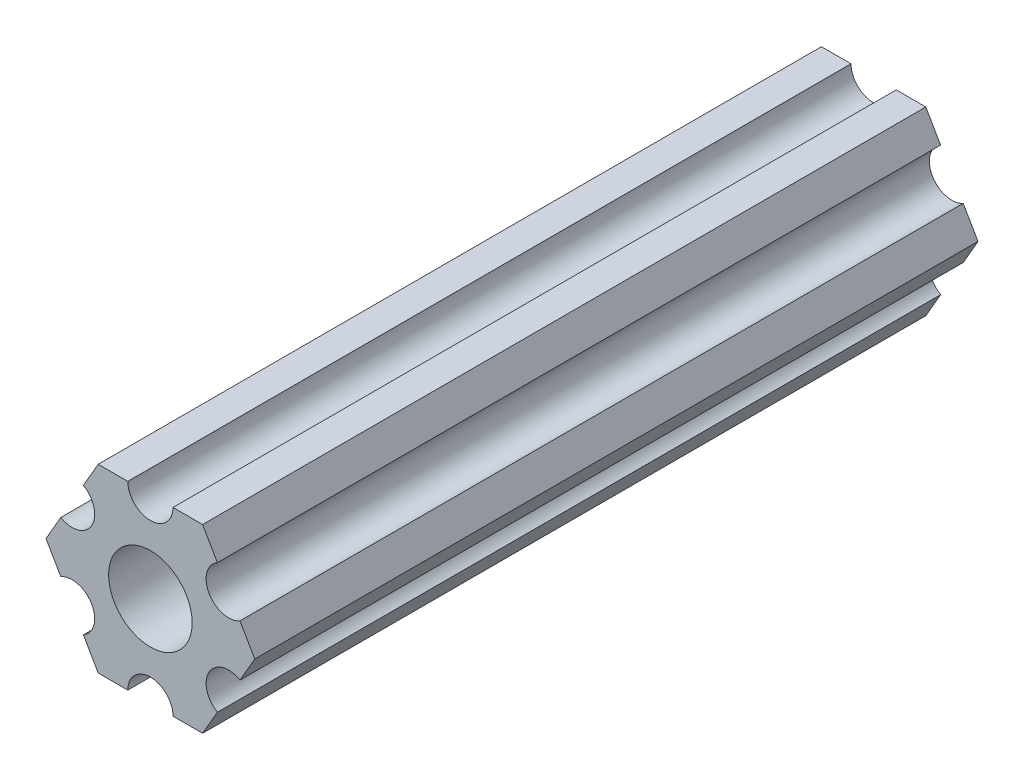
from build123d import *

# Parameters (mm, degrees)
SKETCH1_R           = 2.9337
BOSS_EXTRUDE1_DEPTH = 50.8


with BuildPart() as part:
    # Sketch1 → Boss-Extrude1 (new body)
    with BuildSketch(Plane(origin=(0, 0, 0), x_dir=(-1, 0, 0), z_dir=(0, 0, -1))):
        with BuildLine():
            Line((-4.70551159, -4.549815043), (-3.666174521, -6.349999904))
            Line((-3.666174521, -6.349999904), (-1.587500385, -6.349999904))
            ThreePointArc((-1.587500385, -6.349999904), (-3.85e-07, -4.762499904), (1.587499615, -6.349999904))
            Line((1.587499615, -6.349999904), (3.666173825, -6.349999904))
            Line((3.666173825, -6.349999904), (4.705510942, -4.54981524))
            ThreePointArc((4.705510942, -4.54981524), (4.124445629, -2.381249907), (6.293010962, -1.800184594))
            Line((6.293010962, -1.800184594), (7.332348079, 7e-08))
            Line((7.332348079, 7e-08), (6.293011217, 1.800184685))
            ThreePointArc((6.293011217, 1.800184685), (4.124445939, 2.381250203), (4.705511457, 4.549815481))
            Line((4.705511457, 4.549815481), (3.666174521, 6.350000222))
            Line((3.666174521, 6.350000222), (1.587500385, 6.350000222))
            ThreePointArc((1.587500385, 6.350000222), (3.85e-07, 4.762500222), (-1.587499615, 6.350000222))
            Line((-1.587499615, 6.350000222), (-3.666173825, 6.350000222))
            Line((-3.666173825, 6.350000222), (-4.705511038, 4.549815614))
            ThreePointArc((-4.705511038, 4.549815614), (-4.124445841, 2.38125025), (-6.293011205, 1.800185053))
            Line((-6.293011205, 1.800185053), (-7.332348419, 4.44e-07))
            Line((-7.332348419, 4.44e-07), (-6.293011423, -1.80018429))
            ThreePointArc((-6.293011423, -1.80018429), (-4.12444613, -2.38124975), (-4.70551159, -4.549815043))
        make_face()
        Circle(SKETCH1_R, mode=Mode.SUBTRACT)
    extrude(amount=-BOSS_EXTRUDE1_DEPTH)


solid = part.part
